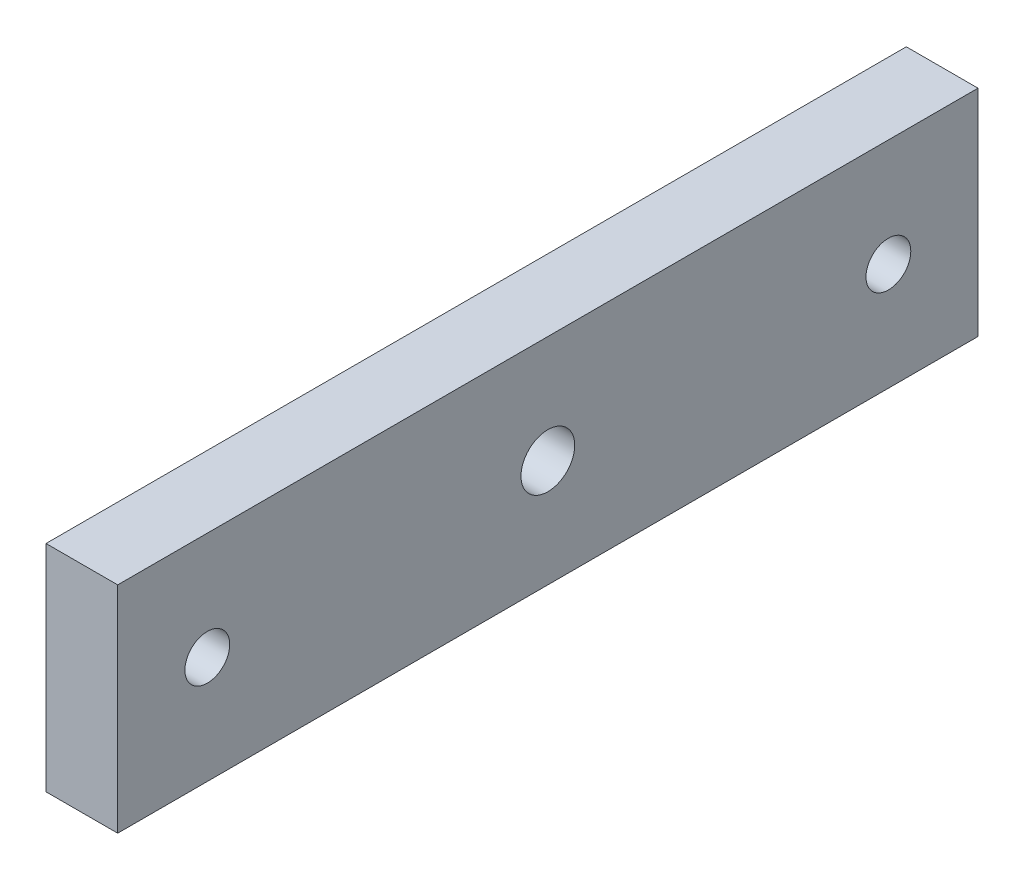
from build123d import *

# Parameters (mm, degrees)
SKETCH1_W                        = 12.7
SKETCH1_H                        = 38.1
EXTRUDE1_DEPTH                   = 76.2
F_3_8_16_TAPPED_HOLE1_D          = 7.9375
F_3_8_16_TAPPED_HOLE1_DEPTH      = 12.7
F_3_8_0_375_DIAMETER_HOLE1_D     = 9.525
F_3_8_0_375_DIAMETER_HOLE1_DEPTH = 12.7
SKETCH6_R                        = 12.827
EXTRUDE2_DEPTH                   = 3.175


with BuildPart() as part:
    # Sketch1 → Extrude1 (new body, symmetric)
    with BuildSketch(Plane.XY):
        Rectangle(SKETCH1_W, SKETCH1_H)
    extrude(amount=EXTRUDE1_DEPTH, both=True)

    # 3/8-16 Tapped Hole1
    with Locations(Plane(origin=(6.35, 0, 0), x_dir=(0, 0, -1), z_dir=(1, 0, 0))):
        with Locations((-60.325, 0), (60.325, 0)):
            Hole(F_3_8_16_TAPPED_HOLE1_D / 2, depth=F_3_8_16_TAPPED_HOLE1_DEPTH)

    # 3/8 (0.375) Diameter Hole1
    with Locations(Plane(origin=(6.35, 0, 0), x_dir=(0, 0, -1), z_dir=(1, 0, 0))):
        with Locations((0, 0)):
            Hole(F_3_8_0_375_DIAMETER_HOLE1_D / 2, depth=F_3_8_0_375_DIAMETER_HOLE1_DEPTH)

    # Sketch6 → Extrude2 (cut)
    with BuildSketch(Plane.ZY.offset(6.35)):
        Circle(SKETCH6_R)
    extrude(amount=-EXTRUDE2_DEPTH, mode=Mode.SUBTRACT)


solid = part.part
